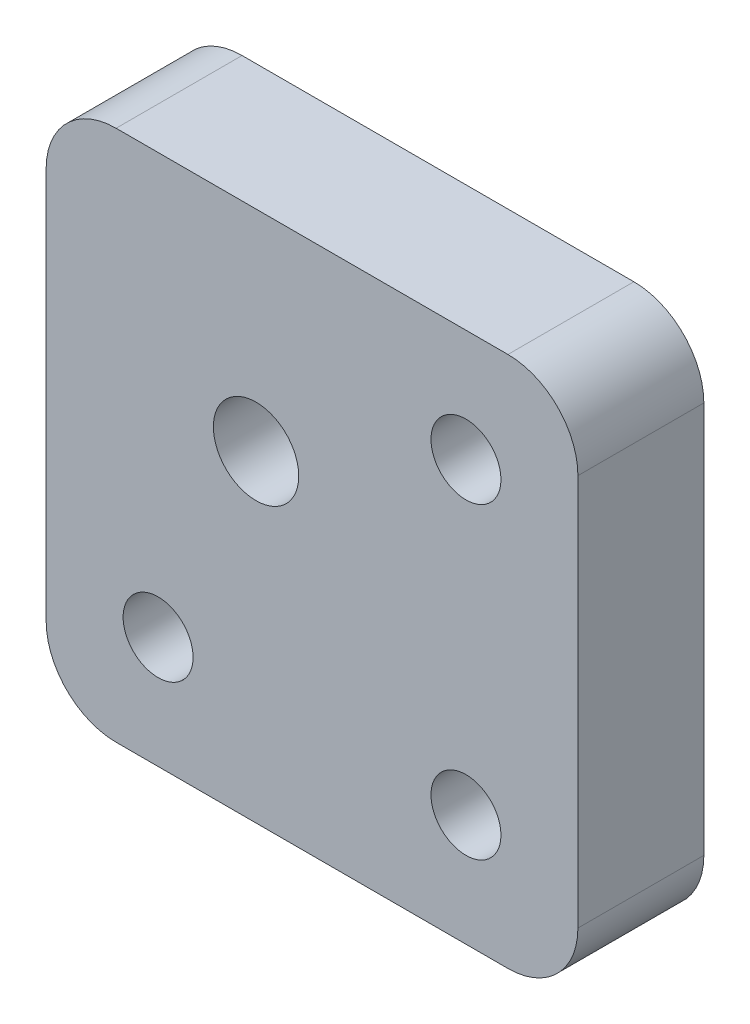
from build123d import *

# Parameters (mm, degrees)
SKETCH_1_W      = 38
SKETCH_1_H      = 38
SKETCH_1_R      = 2.5
SKETCH_1_R_2    = 3.05
EXTRUDE_1_DEPTH = 9
FILLET_1_R      = 5


with BuildPart() as part:
    # 草图1 → 凸台-拉伸1 (new body)
    with BuildSketch(Plane.XY):
        with Locations((-2.169799589, 0.839779006)):
            Rectangle(SKETCH_1_W, SKETCH_1_H)
        with Locations((8.830200411, 11.839779006)):
            Circle(SKETCH_1_R, mode=Mode.SUBTRACT)
        with Locations((8.830200411, -10.160220994)):
            Circle(SKETCH_1_R, mode=Mode.SUBTRACT)
        with Locations((-13.169799589, -10.160220994)):
            Circle(SKETCH_1_R, mode=Mode.SUBTRACT)
        with Locations((-6.169799589, 4.839779006)):
            Circle(SKETCH_1_R_2, mode=Mode.SUBTRACT)
    extrude(amount=EXTRUDE_1_DEPTH)

    # 圆角1
    fillet_1_edges = [part.edges().sort_by_distance(p)[0] for p in [
        (-21.169799589, 19.839779006, 4.5),
        (16.830200411, 19.839779006, 4.5),
        (16.830200411, -18.160220994, 4.5),
        (-21.169799589, -18.160220994, 4.5),
    ]]
    fillet(fillet_1_edges, radius=FILLET_1_R)


solid = part.part
